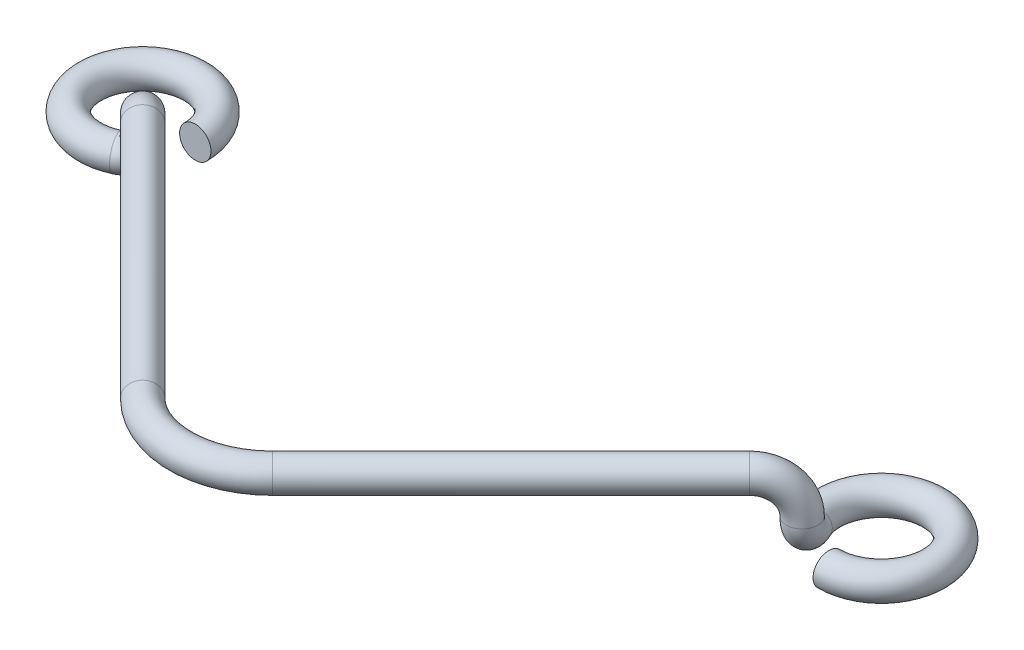
from build123d import *

# Parameters (mm, degrees)
SKETCH4_R = 0.85


with BuildPart() as part:
    # Body: sweep along a curve in space
    with BuildLine() as body_path:
        ThreePointArc((-17.15, 0, -20), (-22.403665621, 0, -21.531303884), (-18.795537954, 0, -17.417022807))
        ThreePointArc((-18.795537954, 0, -17.417022807), (-18.130767909, 0.303822578, -17.72701017), (-17.85541114, 1.037315168, -17.85541114))
        ThreePointArc((-17.85541114, 1.037315168, -17.85541114), (-17.438431689, 2.460972063, -17.438431689), (-16.431754245, 3.050670057, -16.431754245))
        Line((-16.431754245, 3.050670057, -16.431754245), (-3.514552849, 3.050670057, -3.514552849))
        ThreePointArc((-3.514552849, 3.050670057, -3.514552849), (0, 3.050670057, -2.058777393), (3.514552849, 3.050670057, -3.514552849))
        Line((3.514552849, 3.050670057, -3.514552849), (16.431754245, 3.050670057, -16.431754245))
        ThreePointArc((16.431754245, 3.050670057, -16.431754245), (17.438431689, 2.460972063, -17.438431689), (17.85541114, 1.037315168, -17.85541114))
        ThreePointArc((17.85541114, 1.037315168, -17.85541114), (17.72701017, 0.303822578, -18.130767909), (17.417022807, 0, -18.795537954))
        ThreePointArc((17.417022807, 0, -18.795537954), (21.531303884, 0, -22.403665621), (20, 0, -17.15))
    # Sketch4 → Body (sweep)
    with BuildSketch(Plane.XY.offset(-20)):
        with Locations((-17.15, 0)):
            Circle(SKETCH4_R)
    sweep(path=body_path.line)


solid = part.part
